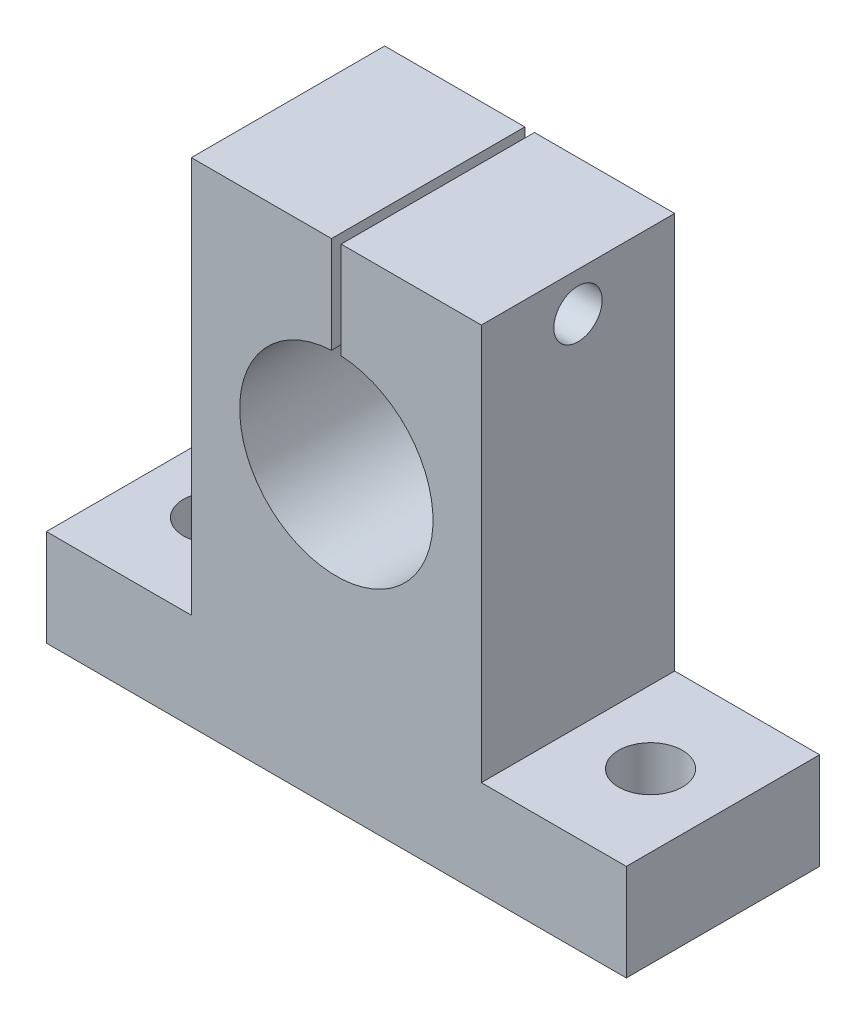
from build123d import *

# Parameters (mm, degrees)
SKETCH1_R           = 10
BOSS_EXTRUDE1_DEPTH = 20
SKETCH3_W           = 1
SKETCH3_H           = 10.850896804
CUT_EXTRUDE1_DEPTH  = 59
SKETCH2_R           = 2.5
CUT_EXTRUDE3_DEPTH  = 31
SKETCH5_R           = 3.3
CUT_EXTRUDE5_DEPTH  = 22


with BuildPart() as part:
    # Sketch1 → Boss-Extrude1 (new body)
    with BuildSketch(Plane.XY):
        Polygon((-30, 0), (30, 0), (30, 10), (15, 10), (15, 51), (-15, 51), (-15, 10), (-30, 10), align=None)
        with Locations((0, 31)):
            Circle(SKETCH1_R, mode=Mode.SUBTRACT)
    extrude(amount=BOSS_EXTRUDE1_DEPTH)

    # Sketch3 → Cut-Extrude1 (cut)
    with BuildSketch(Plane.XY.offset(20)):
        with Locations((0, 45.574551598)):
            Rectangle(SKETCH3_W, SKETCH3_H)
    extrude(amount=-CUT_EXTRUDE1_DEPTH, mode=Mode.SUBTRACT)

    # Sketch2 → Cut-Extrude3 (cut)
    with BuildSketch(Plane(origin=(15, 0, 0), x_dir=(0, 0, -1), z_dir=(1, 0, 0))):
        with Locations((-10, 47)):
            Circle(SKETCH2_R)
    extrude(amount=-CUT_EXTRUDE3_DEPTH, mode=Mode.SUBTRACT)

    # Sketch5 → Cut-Extrude5 (cut)
    with BuildSketch(Plane(origin=(0, 10, 0), x_dir=(1, 0, 0), z_dir=(0, 1, 0))):
        with Locations((22.5, -10)):
            Circle(SKETCH5_R)
        with Locations((-22.5, -10)):
            Circle(SKETCH5_R)
    extrude(amount=-CUT_EXTRUDE5_DEPTH, mode=Mode.SUBTRACT)


solid = part.part
